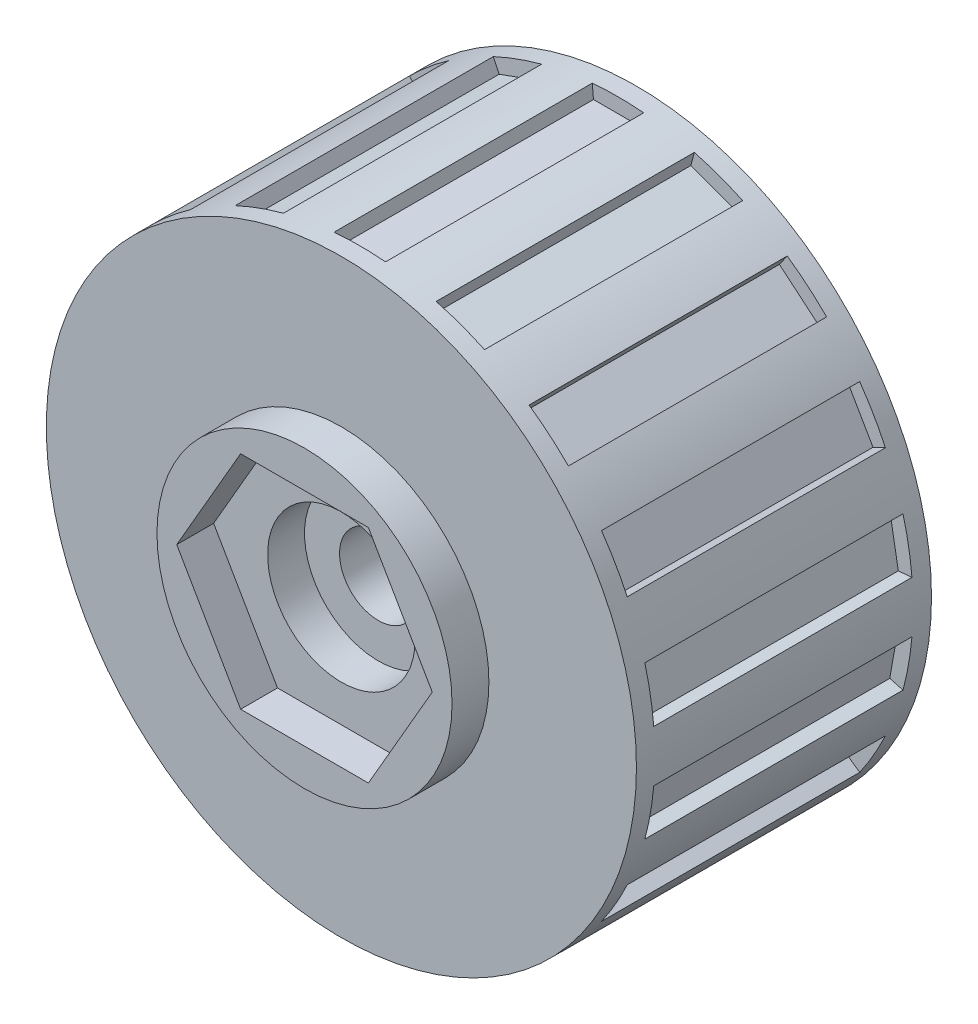
from build123d import *

# Parameters (mm, degrees)
SKETCH_1_R               = 80
SKETCH_1_R_2             = 10.5
EXTRUDE_1_DEPTH          = 80
SKETCH_2_R               = 20
CUT_EXTRUDE_1_DEPTH      = 10
SKETCH_3_R               = 20
CUT_EXTRUDE_2_DEPTH      = 20
CUT_EXTRUDE_3_DEPTH      = 70
PATTERN_CIRCULAR_1_COUNT = 18
SKETCH_6_R               = 35
CUT_EXTRUDE_4_DEPTH      = 10
SKETCH_7_R               = 40
SKETCH_7_R_2             = 20
EXTRUDE_2_DEPTH          = 10
CUT_EXTRUDE_5_DEPTH      = 10


with BuildPart() as part:
    # 草图1 → 凸台-拉伸1 (new body)
    with BuildSketch(Plane.XY):
        Circle(SKETCH_1_R)
        Circle(SKETCH_1_R_2, mode=Mode.SUBTRACT)
    extrude(amount=EXTRUDE_1_DEPTH)

    # 草图2 → 切除-拉伸1 (cut)
    with BuildSketch(Plane.XY.offset(80)):
        Circle(SKETCH_2_R)
    extrude(amount=-CUT_EXTRUDE_1_DEPTH, mode=Mode.SUBTRACT)

    # 草图3 → 切除-拉伸2 (cut)
    with BuildSketch(Plane(origin=(0, 0, 0), x_dir=(-1, 0, 0), z_dir=(0, 0, -1))):
        Circle(SKETCH_3_R)
    extrude(amount=-CUT_EXTRUDE_2_DEPTH, mode=Mode.SUBTRACT)

    # 草图4 → 切除-拉伸3 (cut)
    with BuildSketch(Plane(origin=(0, 0, 5), x_dir=(-1, 0, 0), z_dir=(0, 0, -1))):
        with BuildLine():
            Line((-6.649138428, 76), (-6.97245942, 79.695575847))
            ThreePointArc((-6.97245942, 79.695575847), (0, 80), (6.97245942, 79.695575847))
            Line((6.97245942, 79.695575847), (6.649138428, 76))
            Line((6.649138428, 76), (-6.649138428, 76))
        make_face()
    cut_extrude_3 = extrude(amount=-CUT_EXTRUDE_3_DEPTH, mode=Mode.SUBTRACT)

    # 阵列(圆周)1: 切除-拉伸3 ×18 about axis
    pattern_circular_1_axis = Axis((0, 0, 0), (0, 0, 1))
    for i in range(1, PATTERN_CIRCULAR_1_COUNT):
        add(cut_extrude_3.rotate(pattern_circular_1_axis, i * 360 / PATTERN_CIRCULAR_1_COUNT), mode=Mode.SUBTRACT)

    # 草图6 → 切除-拉伸4 (cut)
    with BuildSketch(Plane(origin=(0, 0, 0), x_dir=(-1, 0, 0), z_dir=(0, 0, -1))):
        Circle(SKETCH_6_R)
    extrude(amount=-CUT_EXTRUDE_4_DEPTH, mode=Mode.SUBTRACT)

    # 草图7 → 凸台-拉伸2 (add)
    with BuildSketch(Plane.XY.offset(80)):
        Circle(SKETCH_7_R)
        Circle(SKETCH_7_R_2, mode=Mode.SUBTRACT)
    extrude(amount=EXTRUDE_2_DEPTH)

    # 草图8 → 切除-拉伸5 (cut)
    with BuildSketch(Plane.XY.offset(90)):
        Polygon((34.641016151, 0), (17.320508076, 30), (-17.320508076, 30), (-34.641016151, 0), (-17.320508076, -30), (17.320508076, -30), align=None)
    extrude(amount=-CUT_EXTRUDE_5_DEPTH, mode=Mode.SUBTRACT)


solid = part.part
